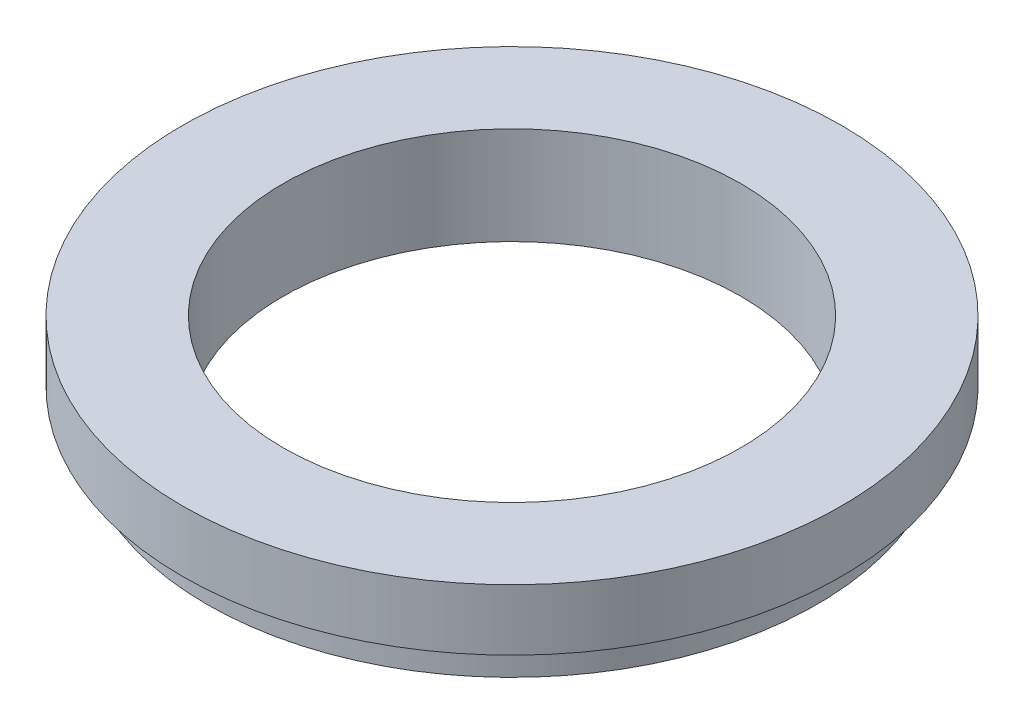
from build123d import *


with BuildPart() as part:
    # Sketch1 → Revolve1 (revolve)
    with BuildSketch(Plane.XY):
        Polygon((6.34619, 0), (6.34619, 0.762), (6.858, 0.762), (6.858, 2.032), (4.7625, 2.032), (4.7625, 0), align=None)
    revolve(axis=Axis((0, 2.032, 0), (0, -1, 0)))


solid = part.part
